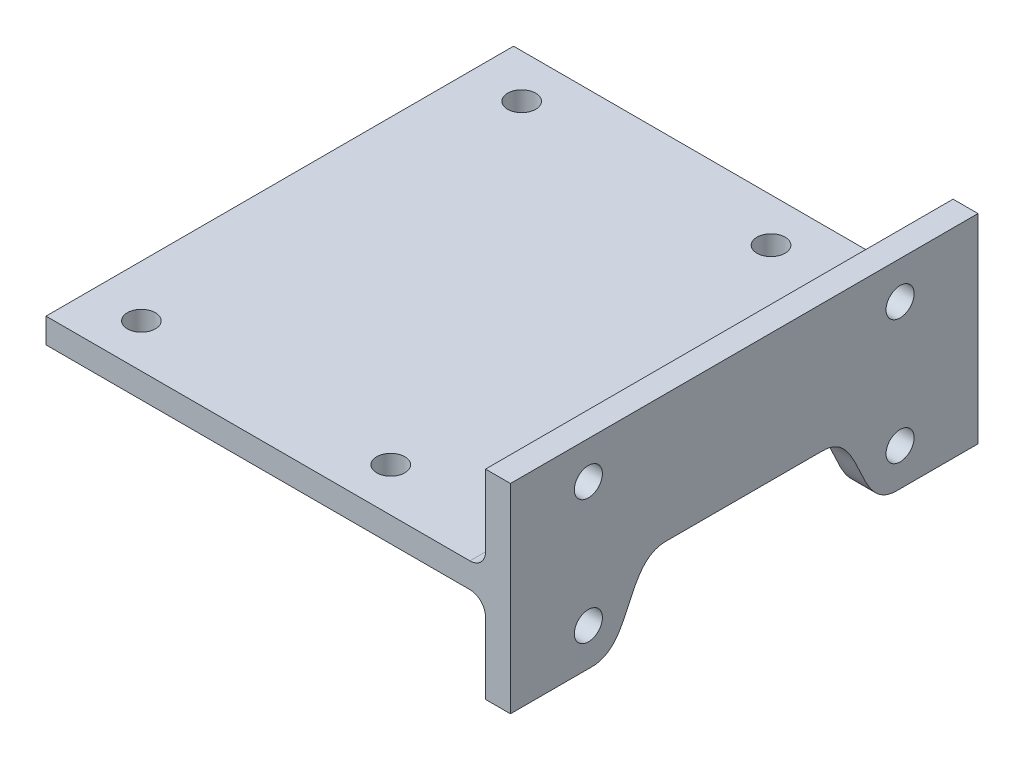
from build123d import *

# Parameters (mm, degrees)
SKETCH2_W           = 141
SKETCH2_H           = 8
SKETCH2_W_2         = 8
SKETCH2_H_2         = 28
BOSS_EXTRUDE1_DEPTH = 150
CUT_EXTRUDE1_REACH  = 38
SKETCH3_R           = 4.5
CUT_EXTRUDE2_REACH  = 151
SKETCH5_R           = 4.5
FILLET1_R           = 5
CUT_EXTRUDE3_REACH  = 10


with BuildPart() as part:
    # Sketch2 → Boss-Extrude1 (new body)
    with BuildSketch(Plane.XY):
        with Locations((70.5, 4)):
            Rectangle(SKETCH2_W, SKETCH2_H)
        with Locations((145, 4)):
            Rectangle(SKETCH2_W_2, SKETCH2_H)
        with Locations((145, 22)):
            Rectangle(SKETCH2_W_2, SKETCH2_H_2)
        with Locations((145, -14)):
            Rectangle(SKETCH2_W_2, SKETCH2_H_2)
    extrude(amount=BOSS_EXTRUDE1_DEPTH)

    # Sketch3 → Cut-Extrude1 (cut, up to next)
    with BuildSketch(Plane.XZ, mode=Mode.PRIVATE) as cut_extrude1_sk1:
        with Locations((96.6, 136)):
            Circle(SKETCH3_R)
    cut_extrude1_tool1 = extrude(cut_extrude1_sk1.sketch, amount=-CUT_EXTRUDE1_REACH, mode=Mode.PRIVATE) & part.part
    add(cut_extrude1_tool1.solids().sort_by_distance((96.6, 0, 136))[0], mode=Mode.SUBTRACT)
    # Sketch3 → Cut-Extrude1 (cut, up to next)
    with BuildSketch(Plane.XZ, mode=Mode.PRIVATE) as cut_extrude1_sk2:
        with Locations((16.6, 136)):
            Circle(SKETCH3_R)
    cut_extrude1_tool2 = extrude(cut_extrude1_sk2.sketch, amount=-CUT_EXTRUDE1_REACH, mode=Mode.PRIVATE) & part.part
    add(cut_extrude1_tool2.solids().sort_by_distance((16.6, 0, 136))[0], mode=Mode.SUBTRACT)
    # Sketch3 → Cut-Extrude1 (cut, up to next)
    with BuildSketch(Plane.XZ, mode=Mode.PRIVATE) as cut_extrude1_sk3:
        with Locations((16.6, 14)):
            Circle(SKETCH3_R)
    cut_extrude1_tool3 = extrude(cut_extrude1_sk3.sketch, amount=-CUT_EXTRUDE1_REACH, mode=Mode.PRIVATE) & part.part
    add(cut_extrude1_tool3.solids().sort_by_distance((16.6, 0, 14))[0], mode=Mode.SUBTRACT)
    # Sketch3 → Cut-Extrude1 (cut, up to next)
    with BuildSketch(Plane.XZ, mode=Mode.PRIVATE) as cut_extrude1_sk4:
        with Locations((96.6, 14)):
            Circle(SKETCH3_R)
    cut_extrude1_tool4 = extrude(cut_extrude1_sk4.sketch, amount=-CUT_EXTRUDE1_REACH, mode=Mode.PRIVATE) & part.part
    add(cut_extrude1_tool4.solids().sort_by_distance((96.6, 0, 14))[0], mode=Mode.SUBTRACT)

    # Sketch5 → Cut-Extrude2 (cut, up to next)
    with BuildSketch(Plane(origin=(149, 0, 0), x_dir=(0, 0, -1), z_dir=(1, 0, 0)), mode=Mode.PRIVATE) as cut_extrude2_sk1:
        with Locations((-125, 24)):
            Circle(SKETCH5_R)
    cut_extrude2_tool1 = extrude(cut_extrude2_sk1.sketch, amount=-CUT_EXTRUDE2_REACH, mode=Mode.PRIVATE) & part.part
    add(cut_extrude2_tool1.solids().sort_by_distance((149, 24, 125))[0], mode=Mode.SUBTRACT)
    # Sketch5 → Cut-Extrude2 (cut, up to next)
    with BuildSketch(Plane(origin=(149, 0, 0), x_dir=(0, 0, -1), z_dir=(1, 0, 0)), mode=Mode.PRIVATE) as cut_extrude2_sk2:
        with Locations((-25, 24)):
            Circle(SKETCH5_R)
    cut_extrude2_tool2 = extrude(cut_extrude2_sk2.sketch, amount=-CUT_EXTRUDE2_REACH, mode=Mode.PRIVATE) & part.part
    add(cut_extrude2_tool2.solids().sort_by_distance((149, 24, 25))[0], mode=Mode.SUBTRACT)
    # Sketch5 → Cut-Extrude2 (cut, up to next)
    with BuildSketch(Plane(origin=(149, 0, 0), x_dir=(0, 0, -1), z_dir=(1, 0, 0)), mode=Mode.PRIVATE) as cut_extrude2_sk3:
        with Locations((-25, -16)):
            Circle(SKETCH5_R)
    cut_extrude2_tool3 = extrude(cut_extrude2_sk3.sketch, amount=-CUT_EXTRUDE2_REACH, mode=Mode.PRIVATE) & part.part
    add(cut_extrude2_tool3.solids().sort_by_distance((149, -16, 25))[0], mode=Mode.SUBTRACT)
    # Sketch5 → Cut-Extrude2 (cut, up to next)
    with BuildSketch(Plane(origin=(149, 0, 0), x_dir=(0, 0, -1), z_dir=(1, 0, 0)), mode=Mode.PRIVATE) as cut_extrude2_sk4:
        with Locations((-125, -16)):
            Circle(SKETCH5_R)
    cut_extrude2_tool4 = extrude(cut_extrude2_sk4.sketch, amount=-CUT_EXTRUDE2_REACH, mode=Mode.PRIVATE) & part.part
    add(cut_extrude2_tool4.solids().sort_by_distance((149, -16, 125))[0], mode=Mode.SUBTRACT)

    # Fillet1
    fillet1_edges = [part.edges().sort_by_distance(p)[0] for p in [
        (141, 8, 75),
        (141, 0, 75),
    ]]
    fillet(fillet1_edges, radius=FILLET1_R)

    # Sketch6 → Cut-Extrude3 (cut, up to next)
    with BuildSketch(Plane.ZY.offset(-141), mode=Mode.PRIVATE) as cut_extrude3_sk1:
        with BuildLine():
            Line((50, -5), (100, -5))
            add(Edge.make_bspline(
                [(124, -28), (117.235743552, -28), (112, -16.5), (106.764256448, -5), (100, -5)],
                knots=[0, 0, 0, 0, 0.5, 1, 1, 1, 1], degree=3))
            Line((124, -28), (26, -28))
            add(Edge.make_bspline(
                [(26, -28), (32.764256448, -28), (38, -16.5), (43.235743552, -5), (50, -5)],
                knots=[0, 0, 0, 0, 0.5, 1, 1, 1, 1], degree=3))
        make_face()
    cut_extrude3_tool1 = extrude(cut_extrude3_sk1.sketch, amount=-CUT_EXTRUDE3_REACH, mode=Mode.PRIVATE) & part.part
    add(cut_extrude3_tool1.solids().sort_by_distance((141, -17.262694, 75))[0], mode=Mode.SUBTRACT)


solid = part.part
